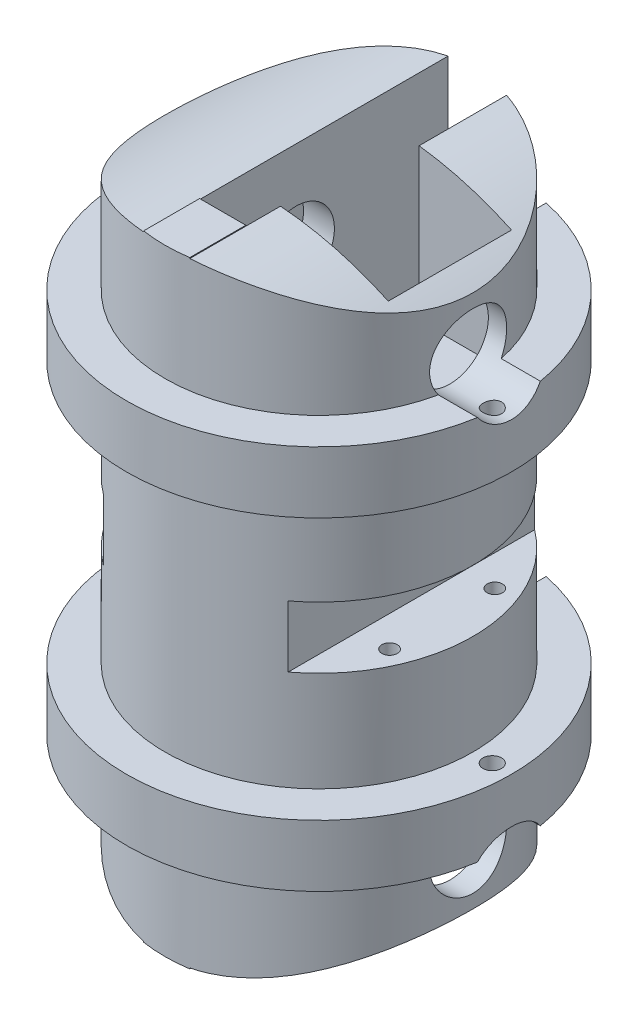
from build123d import *

# Parameters (mm, degrees)
SKETCH1_R           = 10
BOSS_EXTRUDE1_DEPTH = 20
SKETCH2_R           = 24.856075314
SKETCH2_R_2         = 20
CUT_EXTRUDE3_DEPTH  = 20
SKETCH5_W           = 3
SKETCH5_H           = 20
CUT_EXTRUDE4_DEPTH  = 10
CUT_EXTRUDE5_START  = -20
SKETCH6_R           = 2.5
CUT_EXTRUDE5_DEPTH  = 25
SKETCH7_W           = 7
SKETCH7_H           = 8
CUT_EXTRUDE7_DEPTH  = 10
SKETCH8_R           = 0.5
CUT_EXTRUDE8_DEPTH  = 30
SKETCH9_W           = 2
SKETCH9_H           = 7.475145823
CUT_EXTRUDE9_DEPTH  = 23
SKETCH10_W          = 3
SKETCH10_H          = 24.206915905
CUT_EXTRUDE10_DEPTH = 2.5
SKETCH12_W          = 4
SKETCH12_H          = 4
CUT_EXTRUDE12_DEPTH = 15
BOSS_EXTRUDE7_DEPTH = 4
SKETCH39_R          = 2.5
CUT_EXTRUDE15_DEPTH = 12.5
BOSS_EXTRUDE8_DEPTH = 12.5
SKETCH42_R          = 0.6
CUT_EXTRUDE16_DEPTH = 33.5


with BuildPart() as part:
    # Sketch1 → Boss-Extrude1 (new body, symmetric)
    with BuildSketch(Plane(origin=(0, 0, 0), x_dir=(1, 0, 0), z_dir=(0, 1, 0))):
        Circle(SKETCH1_R)
    extrude(amount=BOSS_EXTRUDE1_DEPTH, both=True)

    # Sketch2 → Cut-Extrude3 (cut, symmetric)
    with BuildSketch(Plane.XY):
        Circle(SKETCH2_R)
        Circle(SKETCH2_R_2, mode=Mode.SUBTRACT)
    cut_extrude3 = extrude(amount=CUT_EXTRUDE3_DEPTH, both=True, mode=Mode.SUBTRACT)

    # Sketch5 → Cut-Extrude4 (cut)
    with BuildSketch(Plane(origin=(0, 20, 0), x_dir=(1, 0, 0), z_dir=(0, 1, 0))):
        Rectangle(SKETCH5_W, SKETCH5_H)
    cut_extrude4 = extrude(amount=-CUT_EXTRUDE4_DEPTH, mode=Mode.SUBTRACT)

    # Sketch6 → Cut-Extrude5 (cut)
    with BuildSketch(Plane.ZY.offset(-1.5).offset(CUT_EXTRUDE5_START)):
        with Locations((0, 13.943670675)):
            Circle(SKETCH6_R)
    cut_extrude5 = extrude(amount=CUT_EXTRUDE5_DEPTH, mode=Mode.SUBTRACT)

    # Sketch7 → Cut-Extrude7 (cut)
    with BuildSketch(Plane(origin=(0, 20, 0), x_dir=(1, 0, 0), z_dir=(0, 1, 0))):
        with Locations((5, 0)):
            Rectangle(SKETCH7_W, SKETCH7_H)
    cut_extrude7 = extrude(amount=-CUT_EXTRUDE7_DEPTH, mode=Mode.SUBTRACT)

    # Sketch8 → Cut-Extrude8 (cut)
    with BuildSketch(Plane(origin=(0, 10, 0), x_dir=(1, 0, 0), z_dir=(0, 1, 0))):
        with Locations((8, -3.414911062)):
            Circle(SKETCH8_R)
    cut_extrude8 = extrude(amount=-CUT_EXTRUDE8_DEPTH, mode=Mode.SUBTRACT)

    # Sketch9 → Cut-Extrude9 (cut)
    with BuildSketch(Plane(origin=(0, 10, 0), x_dir=(1, 0, 0), z_dir=(0, 1, 0))):
        with Locations((1.5, 7.737572912)):
            Rectangle(SKETCH9_W, SKETCH9_H)
    cut_extrude9 = extrude(amount=CUT_EXTRUDE9_DEPTH, mode=Mode.SUBTRACT)

    # Mirror2: Cut-Extrude3, Cut-Extrude4, Cut-Extrude5, Cut-Extrude7, Cut-Extrude8, Cut-Extrude9 across plane
    add(cut_extrude3.mirror(Plane.ZX), mode=Mode.SUBTRACT)
    add(cut_extrude4.mirror(Plane.ZX), mode=Mode.SUBTRACT)
    add(cut_extrude5.mirror(Plane.ZX), mode=Mode.SUBTRACT)
    add(cut_extrude7.mirror(Plane.ZX), mode=Mode.SUBTRACT)
    add(cut_extrude8.mirror(Plane.ZX), mode=Mode.SUBTRACT)
    add(cut_extrude9.mirror(Plane.ZX), mode=Mode.SUBTRACT)

    # Mirror3: Cut-Extrude8 across plane
    add(cut_extrude8.mirror(Plane.XY), mode=Mode.SUBTRACT)

    # Sketch10 → Cut-Extrude10 (cut)
    with BuildSketch(Plane(origin=(0, 10, 0), x_dir=(1, 0, 0), z_dir=(0, 1, 0))):
        with Locations((0, 0.041148578)):
            Rectangle(SKETCH10_W, SKETCH10_H)
    cut_extrude10 = extrude(amount=-CUT_EXTRUDE10_DEPTH, mode=Mode.SUBTRACT)

    # Mirror4: Cut-Extrude10 across plane
    add(cut_extrude10.mirror(Plane.ZX), mode=Mode.SUBTRACT)

    # Sketch12 → Cut-Extrude12 (cut, symmetric)
    with BuildSketch(Plane.XY):
        with Locations((-8, 0)):
            Rectangle(SKETCH12_W, SKETCH12_H)
        with Locations((8, 0)):
            Rectangle(SKETCH12_W, SKETCH12_H)
    extrude(amount=CUT_EXTRUDE12_DEPTH, both=True, mode=Mode.SUBTRACT)

    # Sketch37 → Boss-Extrude7 (add)
    with BuildSketch(Plane(origin=(0, 12.5, 0), x_dir=(1, 0, 0), z_dir=(0, 1, 0))):
        with BuildLine():
            Line((-2.5, 9.682458366), (-2.5, 12.247448714))
            ThreePointArc((-2.5, 12.247448714), (-7.90569415, -9.682458366), (12.5, 0))
            ThreePointArc((12.5, 0), (9.682458366, 7.90569415), (2.5, 12.247448714))
            Line((2.5, 12.247448714), (2.5, 9.682458366))
            ThreePointArc((2.5, 9.682458366), (7.90569415, 6.123724357), (10, 0))
            ThreePointArc((10, 0), (-6.123724357, -7.90569415), (-2.5, 9.682458366))
        make_face()
    boss_extrude7 = extrude(amount=-BOSS_EXTRUDE7_DEPTH)

    # Mirror5: Boss-Extrude7 across plane
    add(boss_extrude7.mirror(Plane.ZX))

    # Sketch39 → Cut-Extrude15 (cut)
    with BuildSketch(Plane(origin=(0, 0, 0), x_dir=(0, 0, -1), z_dir=(1, 0, 0))):
        with Locations((0, 13.943670675)):
            Circle(SKETCH39_R)
        with Locations((0, -13.943670675)):
            Circle(SKETCH39_R)
    extrude(amount=CUT_EXTRUDE15_DEPTH, mode=Mode.SUBTRACT)

    # Sketch41 → Boss-Extrude8 (add)
    with BuildSketch(Plane(origin=(0, 7.5, 0), x_dir=(1, 0, 0), z_dir=(0, 1, 0))):
        with BuildLine():
            Line((1.5, -6.25), (-1.5, -6.25))
            Line((-1.5, -6.25), (-1.5, -9.886859967))
            ThreePointArc((-1.5, -9.886859967), (0, -10), (1.5, -9.886859967))
            Line((1.5, -9.886859967), (1.5, -6.25))
        make_face()
    boss_extrude8 = extrude(amount=BOSS_EXTRUDE8_DEPTH)

    # Mirror6: Boss-Extrude8 across plane
    add(boss_extrude8.mirror(Plane.ZX))

    # Sketch42 → Cut-Extrude16 (cut, through all)
    with BuildSketch(Plane(origin=(0, 12.5, 0), x_dir=(1, 0, 0), z_dir=(0, 1, 0))):
        with Locations((11.25, 0)):
            Circle(SKETCH42_R)
    cut_extrude16 = extrude(amount=-CUT_EXTRUDE16_DEPTH, mode=Mode.SUBTRACT)

    # Mirror7: Cut-Extrude16 across plane
    add(cut_extrude16.mirror(Plane(origin=(0, 0, 0), x_dir=(0, 0, 1), z_dir=(1, 0, 0))), mode=Mode.SUBTRACT)


solid = part.part
